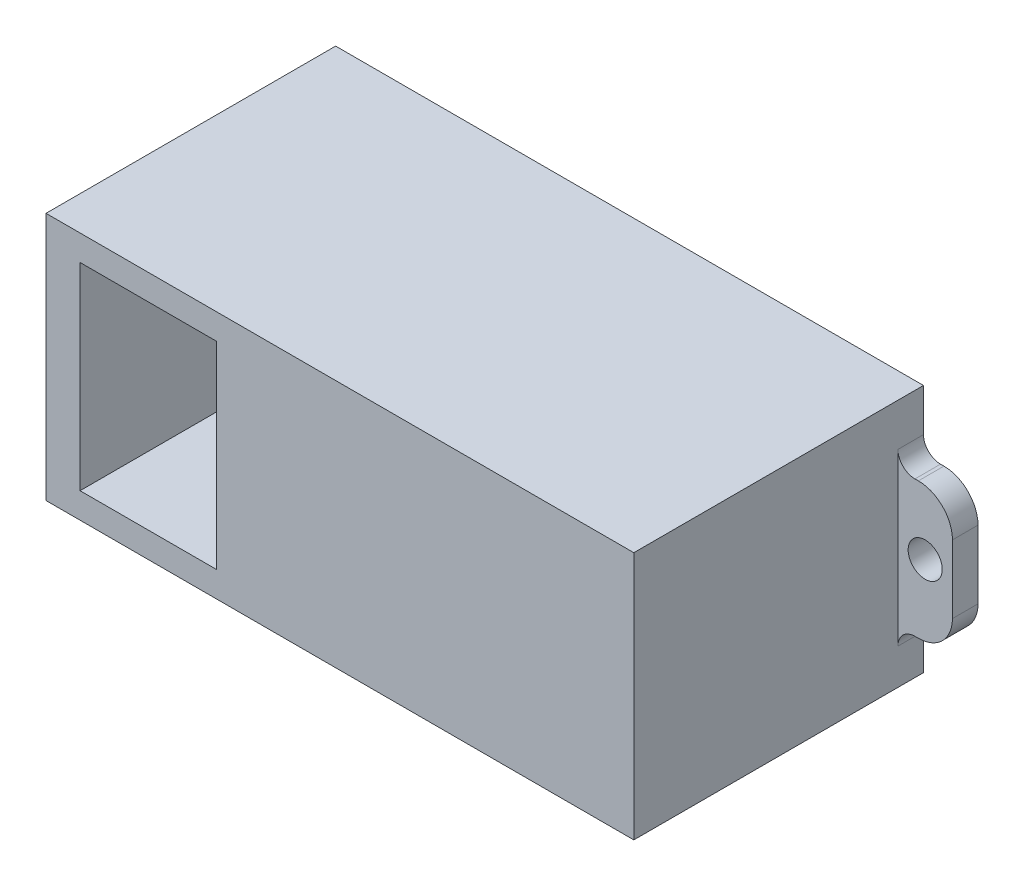
from build123d import *

# Parameters (mm, degrees)
SKETCH1_W           = 22.5
SKETCH1_H           = 12.6
BOSS_EXTRUDE1_DEPTH = 16
SHELL2_T            = 1
SKETCH2_R           = 1
BOSS_EXTRUDE2_DEPTH = 1.5
SKETCH5_W           = 17
SKETCH5_H           = 1.5
BOSS_EXTRUDE3_DEPTH = 10
SKETCH6_W           = 17
SKETCH6_H           = 11.6
BOSS_EXTRUDE4_DEPTH = 2


with BuildPart() as part:
    # Sketch1 → Boss-Extrude1 (new body)
    with BuildSketch(Plane.XY):
        Rectangle(SKETCH1_W, SKETCH1_H)
    extrude(amount=BOSS_EXTRUDE1_DEPTH)

    # Shell2
    shell2_openings = [part.faces().sort_by_distance(p)[0] for p in [
        (0, 0, 0),
    ]]
    offset(amount=SHELL2_T, openings=shell2_openings, kind=Kind.INTERSECTION)

    # Sketch2 → Boss-Extrude2 (add)
    with BuildSketch(Plane(origin=(0, 0, 0), x_dir=(-1, 0, 0), z_dir=(0, 0, -1))):
        with BuildLine():
            Line((-13.45, -4.2), (-13.25, -4.2))
            ThreePointArc((-13.25, -4.2), (-12.542893219, -4.492893219), (-12.25, -5.2))
            Line((-12.25, -5.2), (-12.25, 4.8))
            ThreePointArc((-12.25, 4.8), (-12.542893219, 4.092893219), (-13.25, 3.8))
            Line((-13.25, 3.8), (-13.45, 3.8))
            ThreePointArc((-13.45, 3.8), (-14.864213562, 3.214213562), (-15.45, 1.8))
            Line((-15.45, 1.8), (-15.45, -2.2))
            ThreePointArc((-15.45, -2.2), (-14.864213562, -3.614213562), (-13.45, -4.2))
        make_face()
        with Locations((-13.85, 0)):
            Circle(SKETCH2_R, mode=Mode.SUBTRACT)
    boss_extrude2 = extrude(amount=-BOSS_EXTRUDE2_DEPTH)

    # Mirror1: Boss-Extrude2 across plane
    add(boss_extrude2.mirror(Plane(origin=(0, 0, 0), x_dir=(0, 0, 1), z_dir=(1, 0, 0))))

    # Sketch5 → Boss-Extrude3 (add)
    with BuildSketch(Plane.ZY.offset(12.25)):
        with Locations((8.5, 6.55)):
            Rectangle(SKETCH5_W, SKETCH5_H)
        with Locations((8.5, -6.55)):
            Rectangle(SKETCH5_W, SKETCH5_H)
    extrude(amount=BOSS_EXTRUDE3_DEPTH)

    # Sketch6 → Boss-Extrude4 (add)
    with BuildSketch(Plane.ZY.offset(22.25)):
        with Locations((8.5, 0)):
            Rectangle(SKETCH6_W, SKETCH6_H)
    extrude(amount=-BOSS_EXTRUDE4_DEPTH)


solid = part.part
